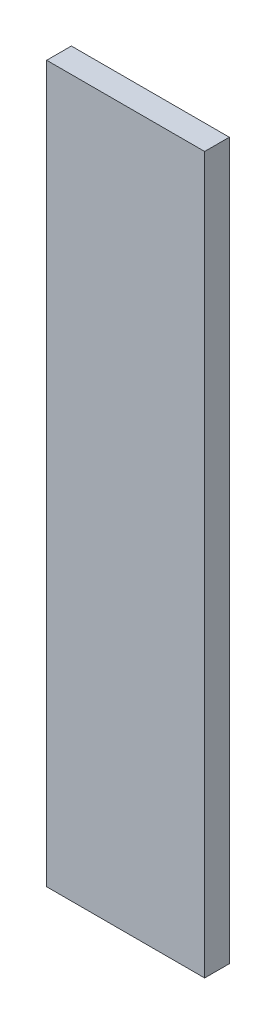
from build123d import *

# Parameters (mm, degrees)
SKETCH1_W           = 96
SKETCH1_H           = 15
BOSS_EXTRUDE1_DEPTH = 435


with BuildPart() as part:
    # Sketch1 → Boss-Extrude1 (new body)
    with BuildSketch(Plane(origin=(0, 0, 0), x_dir=(1, 0, 0), z_dir=(0, 1, 0))):
        Rectangle(SKETCH1_W, SKETCH1_H)
    extrude(amount=BOSS_EXTRUDE1_DEPTH)


solid = part.part
